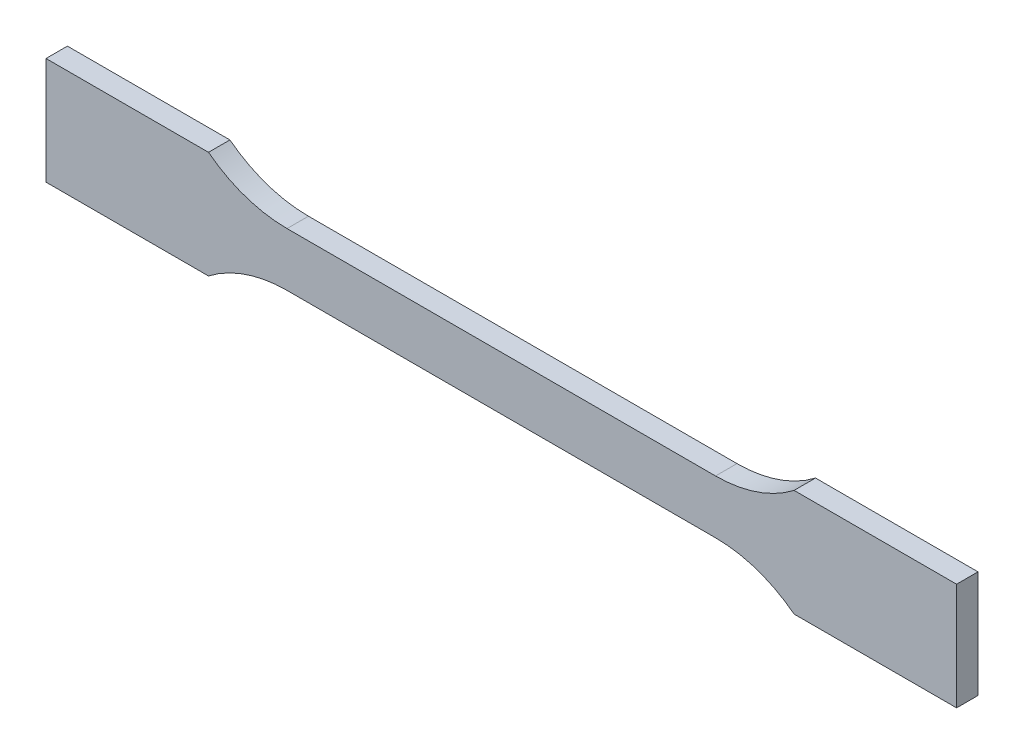
from build123d import *

# Parameters (mm, degrees)
BOSS_EXTRUDE1_DEPTH = 2


with BuildPart() as part:
    # Sketch1 → Boss-Extrude1 (new body, symmetric)
    with BuildSketch(Plane.XY):
        with BuildLine():
            Line((-85, 10), (-85, -10))
            Line((-85, -10), (-54.662878299, -10))
            ThreePointArc((-54.662878299, -10), (-47.745966692, -6.284366617), (-40, -5))
            Line((-40, -5), (40, -5))
            ThreePointArc((40, -5), (47.745966692, -6.284366617), (54.662878299, -10))
            Line((54.662878299, -10), (85, -10))
            Line((85, -10), (85, 10))
            Line((85, 10), (54.662878299, 10))
            ThreePointArc((54.662878299, 10), (47.745966692, 6.284366617), (40, 5))
            Line((40, 5), (-40, 5))
            ThreePointArc((-40, 5), (-47.745966692, 6.284366617), (-54.662878299, 10))
            Line((-54.662878299, 10), (-85, 10))
        make_face()
    extrude(amount=BOSS_EXTRUDE1_DEPTH, both=True)


solid = part.part
